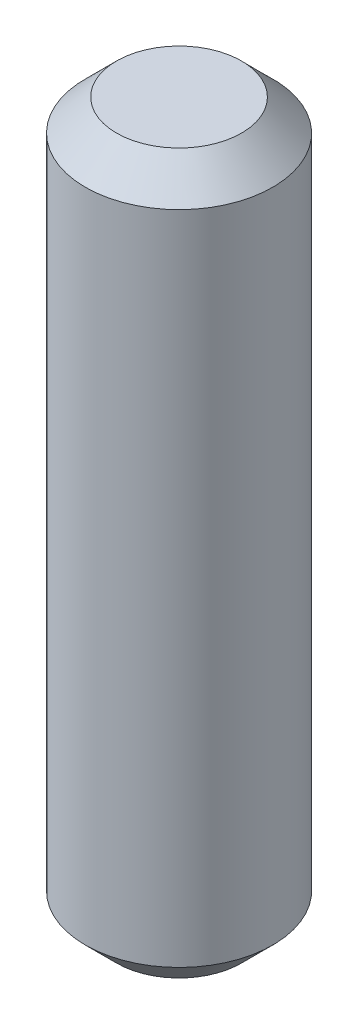
from build123d import *

# Parameters (mm, degrees)
SKETCH1_R           = 3
BOSS_EXTRUDE1_DEPTH = 23
CHAMFER2_SIZE       = 1


with BuildPart() as part:
    # Sketch1 → Boss-Extrude1 (new body)
    with BuildSketch(Plane(origin=(0, 0, 0), x_dir=(1, 0, 0), z_dir=(0, 1, 0))):
        Circle(SKETCH1_R)
    extrude(amount=BOSS_EXTRUDE1_DEPTH)

    # Chamfer2
    chamfer2_edges = [part.edges().sort_by_distance(p)[0] for p in [
        (-3, 0, 0),
        (-3, 23, 0),
    ]]
    chamfer(chamfer2_edges, length=CHAMFER2_SIZE)


solid = part.part
